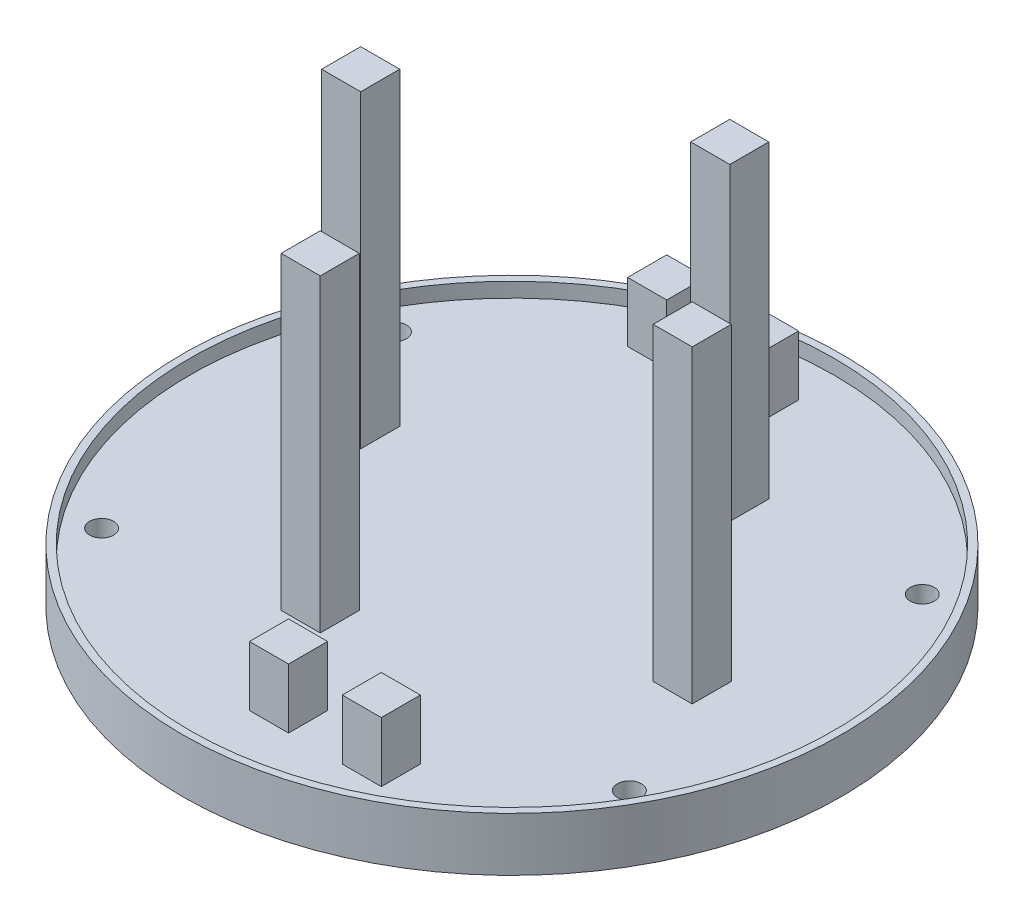
from build123d import *

# Parameters (mm, degrees)
SKETCH1_R                                         = 67.5
BOSS_EXTRUDE1_DEPTH                               = 11
SKETCH2_R                                         = 66
SKETCH2_W                                         = 8
SKETCH2_H                                         = 8
CUT_EXTRUDE1_DEPTH                                = 3
CUT_EXTRUDE2_START                                = -11
SKETCH2_2_R                                       = 66
SKETCH2_2_W                                       = 8
SKETCH2_2_H                                       = 8
CUT_EXTRUDE2_DEPTH                                = 2
CSK_FOR_8_FLAT_HEAD_SOCKET_CAP_SCREW1_D           = 4.9149
CSK_FOR_8_FLAT_HEAD_SOCKET_CAP_SCREW1_CSINK_D     = 9.1186
CSK_FOR_8_FLAT_HEAD_SOCKET_CAP_SCREW1_CSINK_ANGLE = 82
SKETCH11_W                                        = 8
SKETCH11_H                                        = 8
BOSS_EXTRUDE4_DEPTH                               = 63.34
BOSS_EXTRUDE4_2_DEPTH                             = 63.34
BOSS_EXTRUDE4_3_DEPTH                             = 63.34
BOSS_EXTRUDE4_4_DEPTH                             = 63.34
BOSS_EXTRUDE5_DEPTH                               = 12.25


with BuildPart() as part:
    # Sketch1 → Boss-Extrude1 (new body)
    with BuildSketch(Plane(origin=(0, 0, 0), x_dir=(1, 0, 0), z_dir=(0, 1, 0))):
        with Locations(Location((0, 0, 0), (0, 0, 270))):
            Circle(SKETCH1_R)
    extrude(amount=BOSS_EXTRUDE1_DEPTH)

    # Sketch2 → Cut-Extrude1 (cut)
    with BuildSketch(Plane(origin=(0, 11, 0), x_dir=(1, 0, 0), z_dir=(0, 1, 0))):
        with Locations(Location((0, 0, 0), (0, 0, 270))):
            Circle(SKETCH2_R)
        with Locations((-39.420428007, 8.44578543)):
            Rectangle(SKETCH2_W, SKETCH2_H, mode=Mode.SUBTRACT)
        Polygon((-26.242928007, 49.945707301), (-18.242928007, 49.945723937), (-18.242928007, 57.945723937), (-26.242928007, 57.945707301), align=None, mode=Mode.SUBTRACT)
        Polygon((-7.242928007, 49.945746812), (0.757071993, 49.945763449), (0.757071993, 57.945763449), (-7.242928007, 57.945746812), align=None, mode=Mode.SUBTRACT)
        Polygon((7.267071993, 29.351303866), (15.26708835, 29.351303866), (15.267071993, 37.345889008), (7.267071993, 37.34587264), align=None, mode=Mode.SUBTRACT)
        with Locations((39.779571993, -2.85421457)):
            Rectangle(SKETCH2_W, SKETCH2_H, mode=Mode.SUBTRACT)
        Polygon((18.602071993, -53.354153078), (26.602071993, -53.354136441), (26.602071993, -45.354136441), (18.602071993, -45.354153078), align=None, mode=Mode.SUBTRACT)
        Polygon((-0.397928007, -53.354192589), (7.602071993, -53.354175953), (7.602071993, -45.354175953), (-0.397928007, -45.354192589), align=None, mode=Mode.SUBTRACT)
        Polygon((-14.907928007, -32.354318149), (-6.907928007, -32.354301781), (-6.907928007, -24.354301781), (-14.907928007, -24.354318149), align=None, mode=Mode.SUBTRACT)
    extrude(amount=-CUT_EXTRUDE1_DEPTH, mode=Mode.SUBTRACT)

    # Sketch2_2 → Cut-Extrude2 (cut)
    with BuildSketch(Plane(origin=(0, 11, 0), x_dir=(1, 0, 0), z_dir=(0, 1, 0)).offset(CUT_EXTRUDE2_START)):
        with Locations(Location((0, 0, 0), (0, 0, 270))):
            Circle(SKETCH2_2_R)
        with Locations((-39.420428007, 8.44578543)):
            Rectangle(SKETCH2_2_W, SKETCH2_2_H, mode=Mode.SUBTRACT)
        Polygon((-26.242928007, 49.945707301), (-18.242928007, 49.945723937), (-18.242928007, 57.945723937), (-26.242928007, 57.945707301), align=None, mode=Mode.SUBTRACT)
        Polygon((-7.242928007, 49.945746812), (0.757071993, 49.945763449), (0.757071993, 57.945763449), (-7.242928007, 57.945746812), align=None, mode=Mode.SUBTRACT)
        Polygon((7.267071993, 29.351303866), (15.26708835, 29.351303866), (15.267071993, 37.345889008), (7.267071993, 37.34587264), align=None, mode=Mode.SUBTRACT)
        with Locations((39.779571993, -2.85421457)):
            Rectangle(SKETCH2_2_W, SKETCH2_2_H, mode=Mode.SUBTRACT)
        Polygon((18.602071993, -53.354153078), (26.602071993, -53.354136441), (26.602071993, -45.354136441), (18.602071993, -45.354153078), align=None, mode=Mode.SUBTRACT)
        Polygon((-0.397928007, -53.354192589), (7.602071993, -53.354175953), (7.602071993, -45.354175953), (-0.397928007, -45.354192589), align=None, mode=Mode.SUBTRACT)
        Polygon((-14.907928007, -32.354318149), (-6.907928007, -32.354301781), (-6.907928007, -24.354301781), (-14.907928007, -24.354318149), align=None, mode=Mode.SUBTRACT)
    extrude(amount=CUT_EXTRUDE2_DEPTH, mode=Mode.SUBTRACT)

    # CSK for _8 Flat Head Socket Cap Screw1 (through all)
    with Locations(Plane(origin=(0, 2, 0), x_dir=(-1, 0, 0), z_dir=(0, -1, 0))):
        with Locations((52.71405081, 28.657090698), (-47.87752691, 36.162721371), (-52.71405081, -28.657090698), (47.87752691, -36.162721371)):
            CounterSinkHole(CSK_FOR_8_FLAT_HEAD_SOCKET_CAP_SCREW1_D / 2, CSK_FOR_8_FLAT_HEAD_SOCKET_CAP_SCREW1_CSINK_D / 2, counter_sink_angle=CSK_FOR_8_FLAT_HEAD_SOCKET_CAP_SCREW1_CSINK_ANGLE)

    # Sketch12 → Boss-Extrude5 (add)
    with BuildSketch(Plane(origin=(0, 8, 0), x_dir=(1, 0, 0), z_dir=(0, 1, 0))):
        Polygon((18.602071993, -53.354153078), (18.602071993, -45.354153078), (26.602071993, -45.354136441), (26.602071993, -53.354136441), align=None)
        Polygon((7.602071993, -53.354175953), (-0.397928007, -53.354192589), (-0.397928007, -45.354192589), (7.602071993, -45.354175953), align=None)
        Polygon((0.757071993, 57.945763449), (-7.242928007, 57.945746812), (-7.242928007, 49.945746812), (0.757071993, 49.945763449), align=None)
        Polygon((-18.242928007, 57.945723937), (-26.242928007, 57.945707301), (-26.242928007, 49.945707301), (-18.242928007, 49.945723937), align=None)
    extrude(amount=BOSS_EXTRUDE5_DEPTH)


with BuildPart() as body_2:
    # Sketch11 → Boss-Extrude4 (new body)
    with BuildSketch(Plane(origin=(0, 8, 0), x_dir=(1, 0, 0), z_dir=(0, 1, 0))):
        with Locations((-39.420428007, 8.44578543)):
            Rectangle(SKETCH11_W, SKETCH11_H)
    extrude(amount=BOSS_EXTRUDE4_DEPTH)


with BuildPart() as body_3:
    # Sketch11 → Boss-Extrude4 2 (new body)
    with BuildSketch(Plane(origin=(0, 8, 0), x_dir=(1, 0, 0), z_dir=(0, 1, 0))):
        Polygon((7.267071993, 37.34587264), (7.267071993, 29.351303866), (15.26708835, 29.351303866), (15.267071993, 37.345889008), align=None)
    extrude(amount=BOSS_EXTRUDE4_2_DEPTH)


with BuildPart() as body_4:
    # Sketch11 → Boss-Extrude4 3 (new body)
    with BuildSketch(Plane(origin=(0, 8, 0), x_dir=(1, 0, 0), z_dir=(0, 1, 0))):
        with Locations((39.779571993, -2.85421457)):
            Rectangle(SKETCH11_W, SKETCH11_H)
    extrude(amount=BOSS_EXTRUDE4_3_DEPTH)


with BuildPart() as body_5:
    # Sketch11 → Boss-Extrude4 4 (new body)
    with BuildSketch(Plane(origin=(0, 8, 0), x_dir=(1, 0, 0), z_dir=(0, 1, 0))):
        Polygon((-14.907928007, -24.354318149), (-14.907928007, -32.354318149), (-6.907928007, -32.354301781), (-6.907928007, -24.354301781), align=None)
    extrude(amount=BOSS_EXTRUDE4_4_DEPTH)


solid = Compound([part.part, body_2.part, body_3.part, body_4.part, body_5.part])
